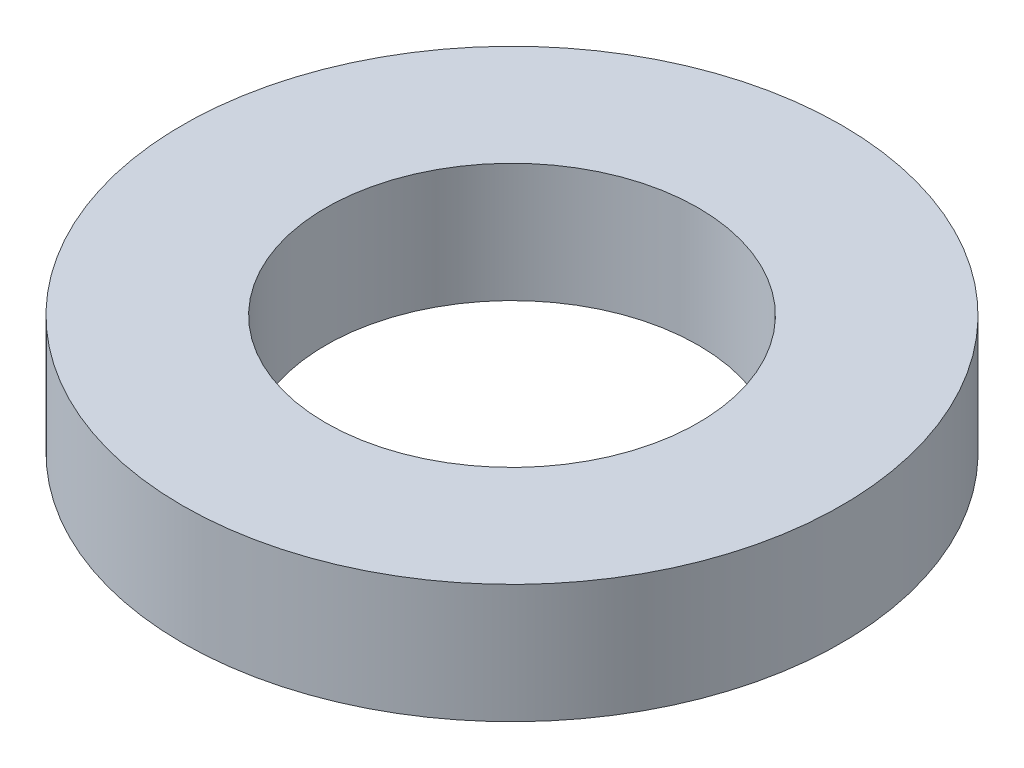
from build123d import *

# Parameters (mm, degrees)
SKETCH1_R           = 5.842
SKETCH1_R_2         = 3.302
BOSS_EXTRUDE1_DEPTH = 2.1082


with BuildPart() as part:
    # Sketch1 → Boss-Extrude1 (new body)
    with BuildSketch(Plane(origin=(0, 0, 0), x_dir=(1, 0, 0), z_dir=(0, 1, 0))):
        Circle(SKETCH1_R)
        Circle(SKETCH1_R_2, mode=Mode.SUBTRACT)
    extrude(amount=BOSS_EXTRUDE1_DEPTH)


solid = part.part
